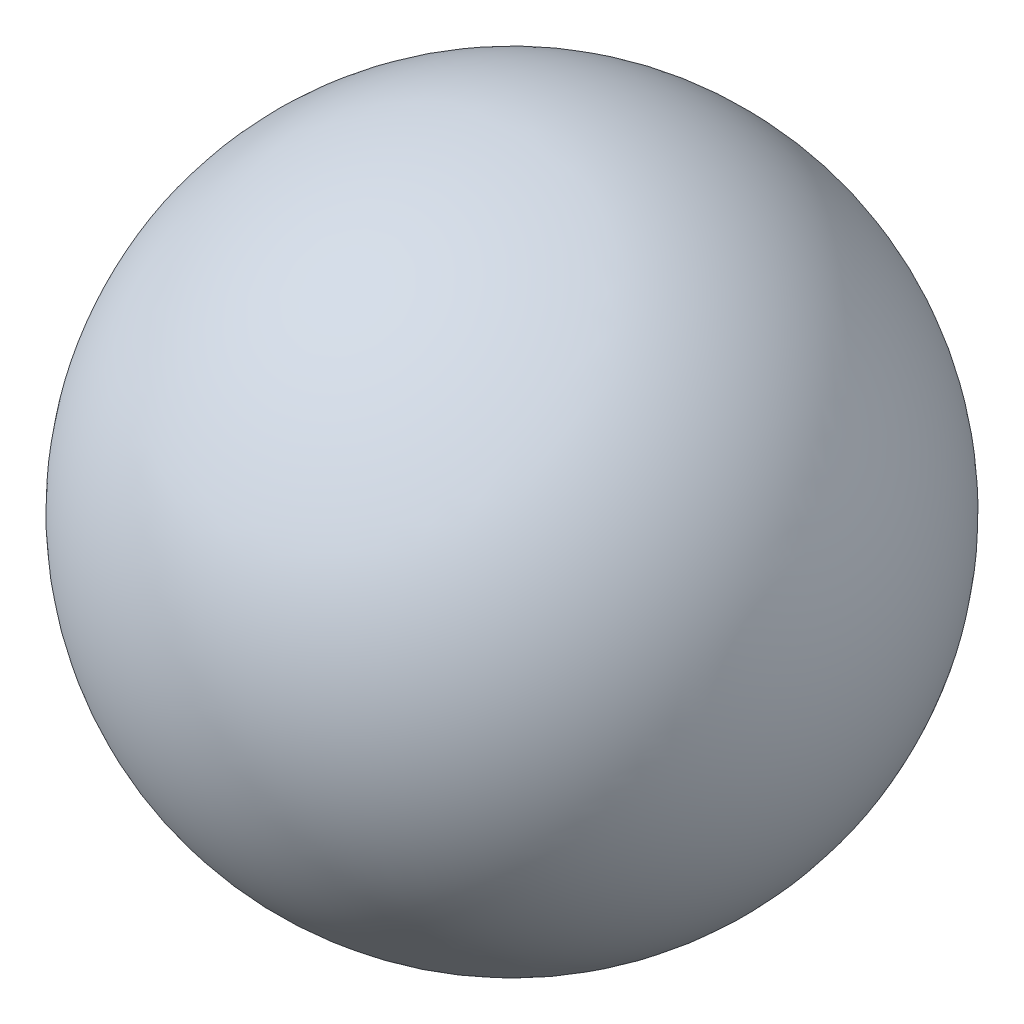
from build123d import *


with BuildPart() as part:
    # Sketch1 → Revolve1 (revolve)
    with BuildSketch(Plane.XY):
        with BuildLine():
            Line((-12.652788897, 0.000513013), (12.745711647, 0.276502427))
            ThreePointArc((12.745711647, 0.276502427), (0.184456082, -12.560742551), (-12.652788897, 0.000513013))
        make_face()
    revolve(axis=Axis((-12.652788897, 0.000513013, 0), (0.999940966, 0.010865725, 0)))


solid = part.part
